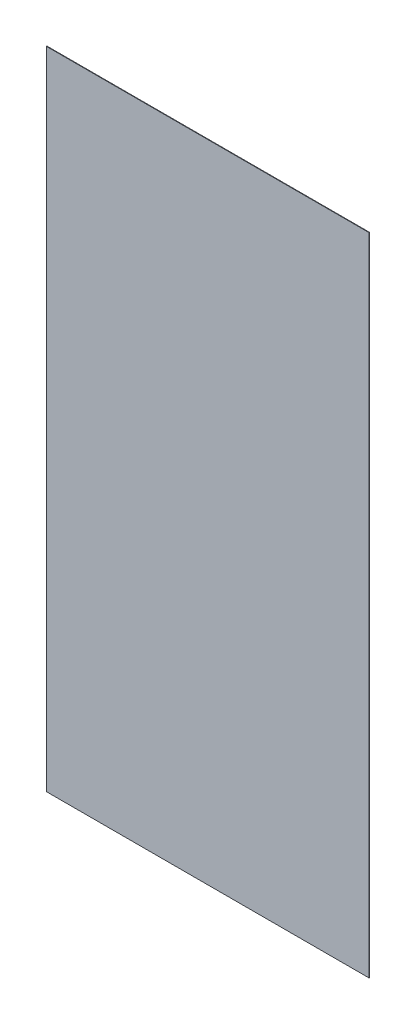
from build123d import *

# Parameters (mm, degrees)
ESQUISSE1_W        = 1250
ESQUISSE1_H        = 2500
BOSS_EXTRU_1_DEPTH = 2


with BuildPart() as part:
    # Esquisse1 → Boss.-Extru.1 (new body)
    with BuildSketch(Plane.XY):
        Rectangle(ESQUISSE1_W, ESQUISSE1_H)
    extrude(amount=BOSS_EXTRU_1_DEPTH)


solid = part.part
